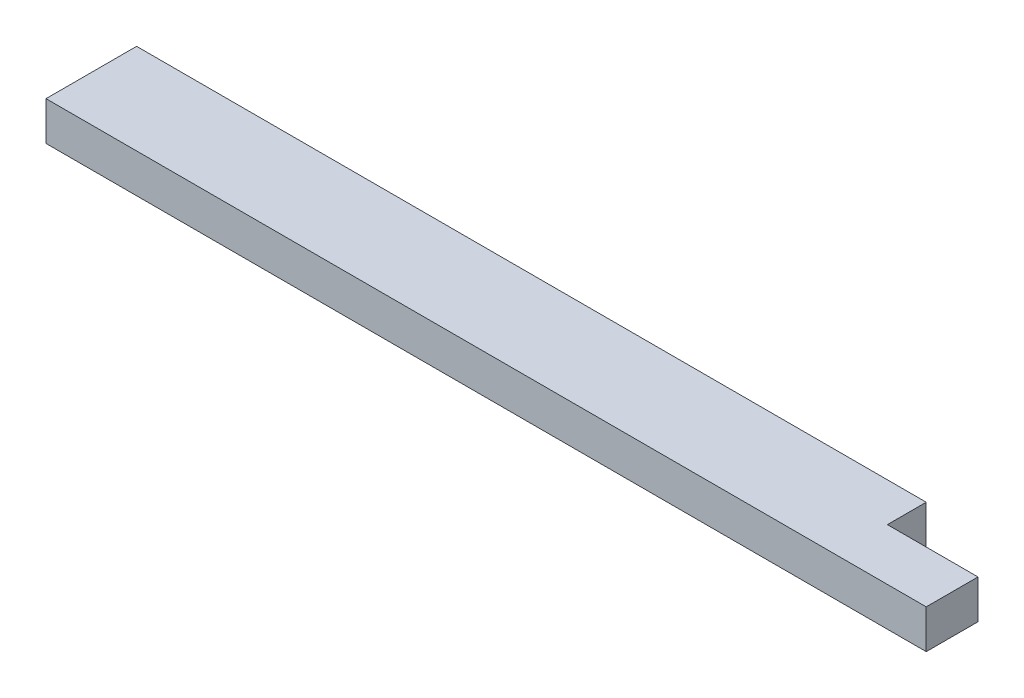
from build123d import *

# Parameters (mm, degrees)
SKETCH1_W           = 863.6
SKETCH1_H           = 88.9
BOSS_EXTRUDE1_DEPTH = 38.1
SKETCH3_W           = 88.9
SKETCH3_H           = 38.1
CUT_EXTRUDE1_DEPTH  = 39.1


with BuildPart() as part:
    # Sketch1 → Boss-Extrude1 (new body)
    with BuildSketch(Plane(origin=(0, 0, 0), x_dir=(1, 0, 0), z_dir=(0, 1, 0))):
        with Locations((431.8, 44.45)):
            Rectangle(SKETCH1_W, SKETCH1_H)
    extrude(amount=BOSS_EXTRUDE1_DEPTH)

    # Sketch3 → Cut-Extrude1 (cut, through all)
    with BuildSketch(Plane(origin=(0, 38.1, 0), x_dir=(1, 0, 0), z_dir=(0, 1, 0))):
        with Locations((819.15, 69.85)):
            Rectangle(SKETCH3_W, SKETCH3_H)
    extrude(amount=-CUT_EXTRUDE1_DEPTH, mode=Mode.SUBTRACT)


solid = part.part
